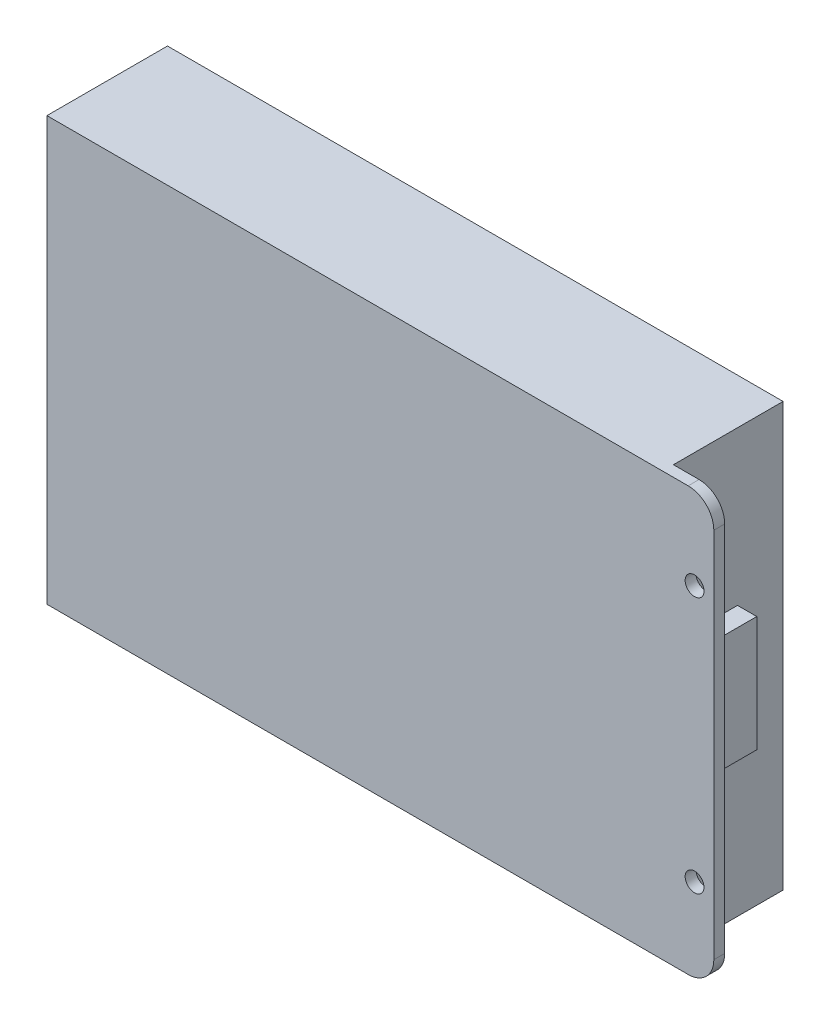
from build123d import *

# Parameters (mm, degrees)
SKETCH1_W           = 96
SKETCH1_H           = 66
BOSS_EXTRUDE1_DEPTH = 17.1
BOSS_EXTRUDE2_DEPTH = 1.7
SKETCH3_W           = 10
SKETCH3_H           = 18
BOSS_EXTRUDE3_DEPTH = 3
SKETCH4_R           = 1.47
CUT_EXTRUDE1_DEPTH  = 19.8


with BuildPart() as part:
    # Sketch1 → Boss-Extrude1 (new body)
    with BuildSketch(Plane.XY):
        Rectangle(SKETCH1_W, SKETCH1_H)
    extrude(amount=BOSS_EXTRUDE1_DEPTH)

    # Sketch2 → Boss-Extrude2 (add)
    with BuildSketch(Plane.XY.offset(17.1)):
        with BuildLine():
            Line((-48, 33), (52, 33))
            ThreePointArc((52, 33), (54.828427125, 31.828427125), (56, 29))
            Line((56, 29), (56, -29))
            ThreePointArc((56, -29), (54.828427125, -31.828427125), (52, -33))
            Line((52, -33), (-48, -33))
            Line((-48, -33), (-48, 33))
        make_face()
    extrude(amount=BOSS_EXTRUDE2_DEPTH)

    # Sketch3 → Boss-Extrude3 (add)
    with BuildSketch(Plane(origin=(48, 0, 0), x_dir=(0, 0, -1), z_dir=(1, 0, 0))):
        with Locations((-12.1, 0)):
            Rectangle(SKETCH3_W, SKETCH3_H)
    extrude(amount=BOSS_EXTRUDE3_DEPTH)

    # Sketch4 → Cut-Extrude1 (cut, through all)
    with BuildSketch(Plane.XY.offset(18.8)):
        with Locations((53, 20)):
            Circle(SKETCH4_R)
        with Locations((53, -20)):
            Circle(SKETCH4_R)
    extrude(amount=-CUT_EXTRUDE1_DEPTH, mode=Mode.SUBTRACT)


solid = part.part
